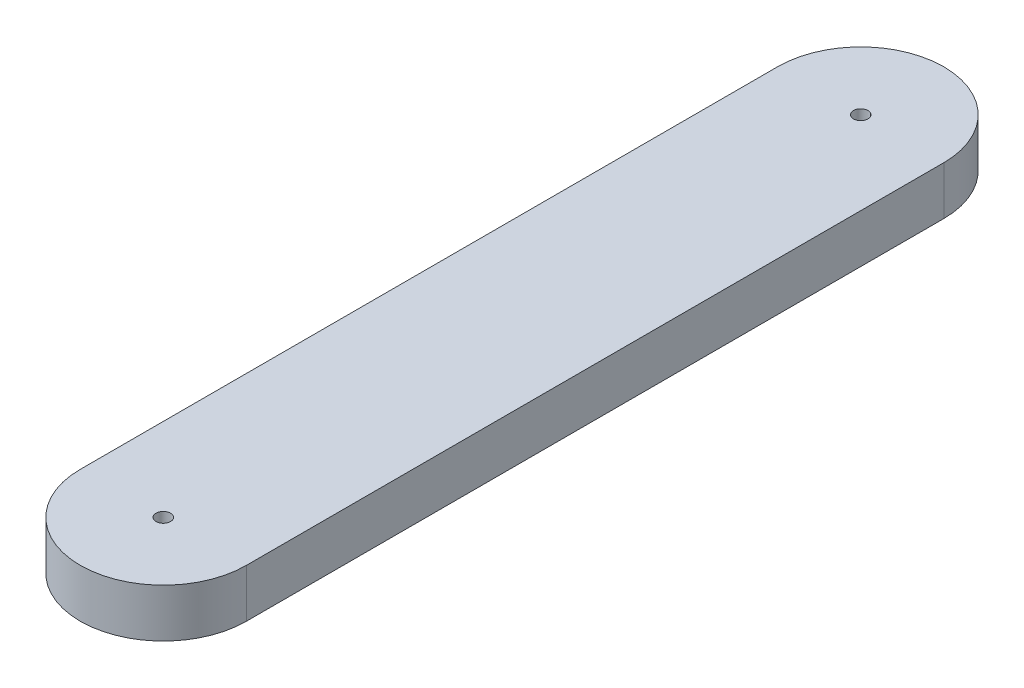
from build123d import *

# Parameters (mm, degrees)
BOSS_EXTRUDE1_DEPTH = 5
SKETCH3_R           = 0.75
CUT_EXTRUDE1_DEPTH  = 3
SKETCH4_R           = 0.75
CUT_EXTRUDE2_DEPTH  = 3


with BuildPart() as part:
    # Sketch2 → Boss-Extrude1 (new body)
    with BuildSketch(Plane(origin=(0, 0, 0), x_dir=(1, 0, 0), z_dir=(0, 1, 0))):
        with BuildLine():
            Line((-27.42, 36), (-27.42, 8.582019714))
            Line((-27.42, 8.582019714), (-27.42, -8.582019714))
            Line((-27.42, -8.582019714), (-27.42, -36))
            ThreePointArc((-27.42, -36), (-36, -44.58), (-44.58, -36))
            Line((-44.58, -36), (-44.58, -8.582019714))
            Line((-44.58, -8.582019714), (-44.58, 8.582019714))
            Line((-44.58, 8.582019714), (-44.58, 36))
            ThreePointArc((-44.58, 36), (-36, 44.58), (-27.42, 36))
        make_face()
    extrude(amount=BOSS_EXTRUDE1_DEPTH)

    # Sketch3 → Cut-Extrude1 (cut)
    with BuildSketch(Plane.XZ):
        with Locations((-36, 0)):
            Circle(SKETCH3_R)
    extrude(amount=-CUT_EXTRUDE1_DEPTH, mode=Mode.SUBTRACT)

    # Sketch4 → Cut-Extrude2 (cut)
    with BuildSketch(Plane(origin=(0, 5, 0), x_dir=(1, 0, 0), z_dir=(0, 1, 0))):
        with Locations((-36, 36)):
            Circle(SKETCH4_R)
        with Locations((-36, -36)):
            Circle(SKETCH4_R)
    extrude(amount=-CUT_EXTRUDE2_DEPTH, mode=Mode.SUBTRACT)


solid = part.part
